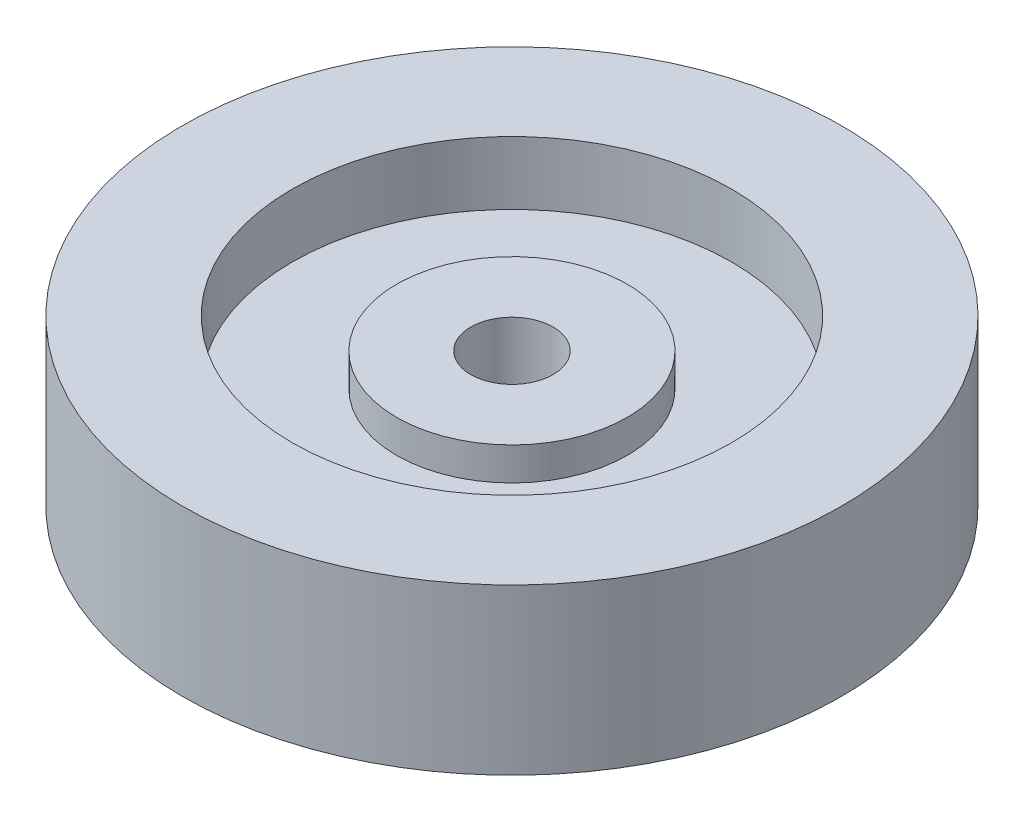
from build123d import *

# Parameters (mm, degrees)
BOSS_EXTRUDE1_DEPTH      = 15
BOSS_EXTRUDE1_DEPTH_BACK = 15
SKETCH2_R                = 60
SKETCH3_R                = 40
CUT_EXTRUDE1_DEPTH       = 11.5
SKETCH4_R                = 21
BOSS_EXTRUDE2_DEPTH      = 6
SKETCH5_R                = 7.5
CUT_EXTRUDE2_DEPTH       = 20


with BuildPart() as part:
    # Sketch2 → Boss-Extrude1 (new, two sides: drawn at the far end of the back side and taken through both)
    with BuildSketch(Plane(origin=(0, 0, 0), x_dir=(1, 0, 0), z_dir=(0, 1, 0)).offset(-BOSS_EXTRUDE1_DEPTH_BACK)):
        Circle(SKETCH2_R)
    extrude(amount=BOSS_EXTRUDE1_DEPTH + BOSS_EXTRUDE1_DEPTH_BACK)

    # Sketch3 → Cut-Extrude1 (cut)
    with BuildSketch(Plane(origin=(0, 15, 0), x_dir=(1, 0, 0), z_dir=(0, 1, 0))):
        Circle(SKETCH3_R)
    cut_extrude1 = extrude(amount=-CUT_EXTRUDE1_DEPTH, mode=Mode.SUBTRACT)

    # Sketch4 → Boss-Extrude2 (add)
    with BuildSketch(Plane(origin=(0, 3.5, 0), x_dir=(1, 0, 0), z_dir=(0, 1, 0))):
        Circle(SKETCH4_R)
    boss_extrude2 = extrude(amount=BOSS_EXTRUDE2_DEPTH)

    # Sketch5 → Cut-Extrude2 (cut)
    with BuildSketch(Plane(origin=(0, 9.5, 0), x_dir=(1, 0, 0), z_dir=(0, 1, 0))):
        Circle(SKETCH5_R)
    cut_extrude2 = extrude(amount=-CUT_EXTRUDE2_DEPTH, mode=Mode.SUBTRACT)

    # Mirror1: Cut-Extrude1, Boss-Extrude2, Cut-Extrude2 across plane
    add(cut_extrude1.mirror(Plane.ZX), mode=Mode.SUBTRACT)
    add(boss_extrude2.mirror(Plane.ZX))
    add(cut_extrude2.mirror(Plane.ZX), mode=Mode.SUBTRACT)


solid = part.part
